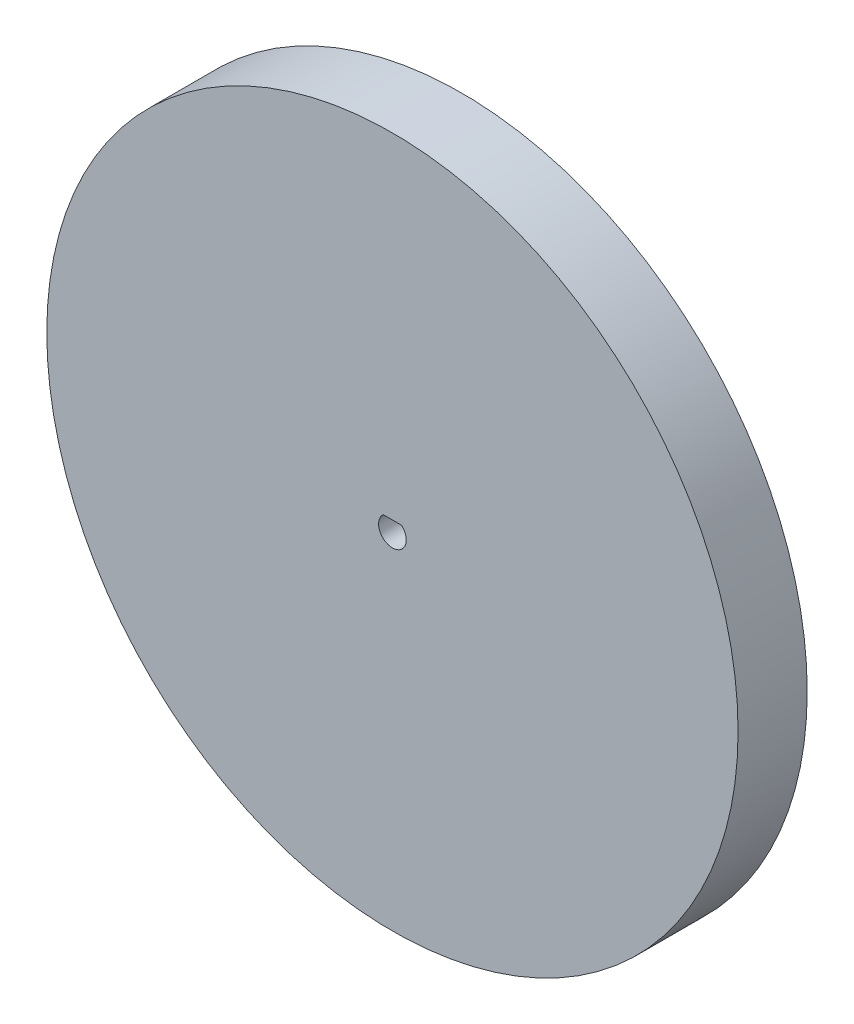
from build123d import *

# Parameters (mm, degrees)
SKETCH1_R           = 50
BOSS_EXTRUDE1_DEPTH = 10


with BuildPart() as part:
    # Sketch1 → Boss-Extrude1 (new body)
    with BuildSketch(Plane.XY):
        Circle(SKETCH1_R)
        with BuildLine():
            Line((-1.322875656, 1.5), (1.322875656, 1.5))
            ThreePointArc((1.322875656, 1.5), (0, -2), (-1.322875656, 1.5))
        make_face(mode=Mode.SUBTRACT)
    extrude(amount=BOSS_EXTRUDE1_DEPTH)


solid = part.part
